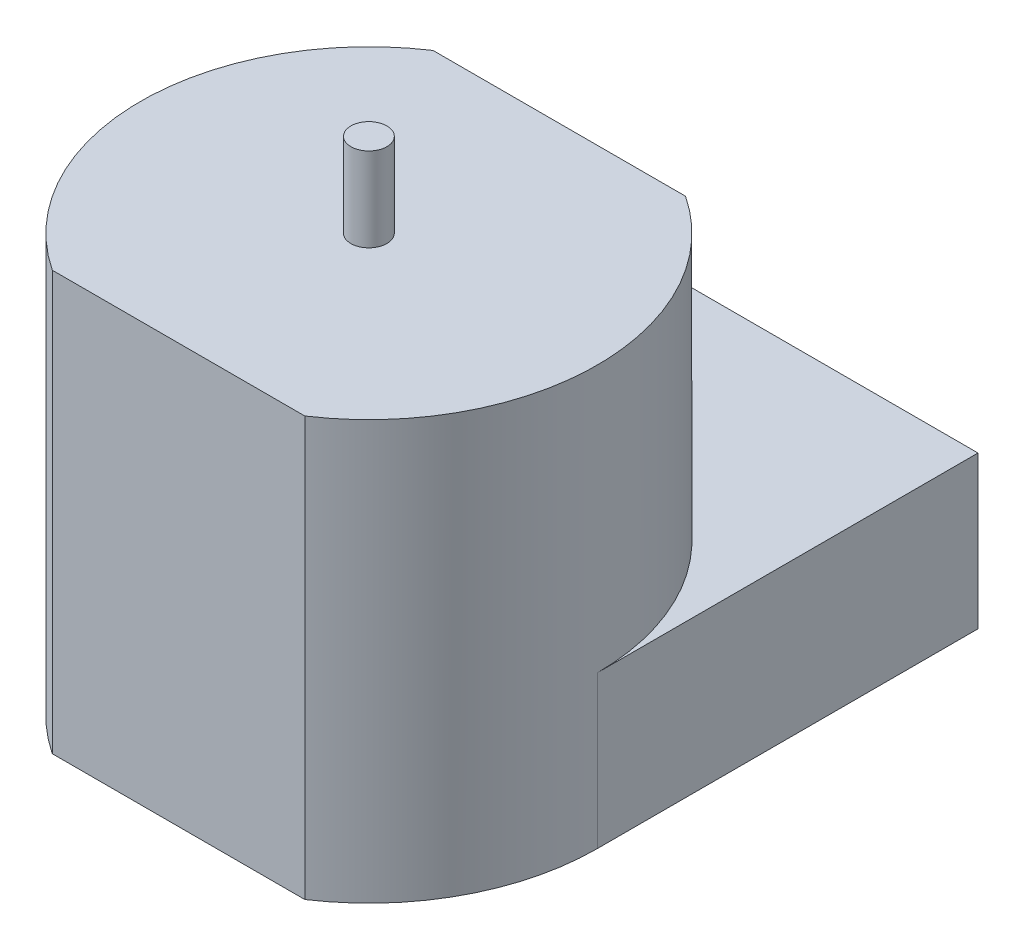
from build123d import *

# Parameters (mm, degrees)
SKETCH1_W           = 10.53028371
SKETCH1_H           = 7.9375
BOSS_EXTRUDE1_DEPTH = 6.35
SKETCH2_W           = 10.53028371
SKETCH2_H           = 15.875
BOSS_EXTRUDE2_DEPTH = 11.1125
SKETCH3_R           = 0.75
BOSS_EXTRUDE3_DEPTH = 3.5


with BuildPart() as part:
    # Sketch1 → Boss-Extrude1 (new body)
    with BuildSketch(Plane(origin=(0, 0, 0), x_dir=(1, 0, 0), z_dir=(0, 1, 0))):
        with BuildLine():
            Line((-5.265141855, 0), (-5.265141855, 7.9375))
            ThreePointArc((-5.265141855, 7.9375), (-8.392737967, 4.504173), (-9.525, 0))
            Line((-9.525, 0), (-5.265141855, 0))
        make_face()
        with BuildLine():
            Line((-5.265141855, -7.9375), (-5.265141855, 0))
            Line((-5.265141855, 0), (-9.525, 0))
            ThreePointArc((-9.525, 0), (-8.392737967, -4.504173), (-5.265141855, -7.9375))
        make_face()
        with Locations((0, -3.96875)):
            Rectangle(SKETCH1_W, SKETCH1_H)
        with BuildLine():
            ThreePointArc((9.525, 0), (8.392737967, 4.504173), (5.265141855, 7.9375))
            Line((5.265141855, 7.9375), (5.265141855, 0))
            Line((5.265141855, 0), (9.525, 0))
        make_face()
        with BuildLine():
            Line((9.525, 0), (5.265141855, 0))
            Line((5.265141855, 0), (5.265141855, -7.9375))
            ThreePointArc((5.265141855, -7.9375), (8.392737967, -4.504173), (9.525, 0))
        make_face()
        with BuildLine():
            ThreePointArc((-9.525, 0), (-8.392737967, 4.504173), (-5.265141855, 7.9375))
            ThreePointArc((-5.265141855, 7.9375), (0, 9.525), (5.265141855, 7.9375))
            ThreePointArc((5.265141855, 7.9375), (8.392737967, 4.504173), (9.525, 0))
            Line((9.525, 0), (9.525, 15.875))
            Line((9.525, 15.875), (-9.525, 15.875))
            Line((-9.525, 15.875), (-9.525, 0))
        make_face()
        with Locations((0, 3.96875)):
            Rectangle(SKETCH1_W, SKETCH1_H)
        with BuildLine():
            ThreePointArc((5.265141855, 7.9375), (0, 9.525), (-5.265141855, 7.9375))
            Line((-5.265141855, 7.9375), (5.265141855, 7.9375))
        make_face()
    extrude(amount=BOSS_EXTRUDE1_DEPTH)

    # Sketch2 → Boss-Extrude2 (add)
    with BuildSketch(Plane(origin=(0, 6.35, 0), x_dir=(1, 0, 0), z_dir=(0, 1, 0))):
        with BuildLine():
            Line((-5.265141855, -7.9375), (-5.265141855, 7.9375))
            ThreePointArc((-5.265141855, 7.9375), (-8.392737967, 4.504173), (-9.525, 0))
            ThreePointArc((-9.525, 0), (-8.392737967, -4.504173), (-5.265141855, -7.9375))
        make_face()
        Rectangle(SKETCH2_W, SKETCH2_H)
        with BuildLine():
            ThreePointArc((9.525, 0), (8.392737967, 4.504173), (5.265141855, 7.9375))
            Line((5.265141855, 7.9375), (5.265141855, -7.9375))
            ThreePointArc((5.265141855, -7.9375), (8.392737967, -4.504173), (9.525, 0))
        make_face()
    extrude(amount=BOSS_EXTRUDE2_DEPTH)

    # Sketch3 → Boss-Extrude3 (add)
    with BuildSketch(Plane(origin=(0, 17.4625, 0), x_dir=(1, 0, 0), z_dir=(0, 1, 0))):
        Circle(SKETCH3_R)
    extrude(amount=BOSS_EXTRUDE3_DEPTH)


solid = part.part
